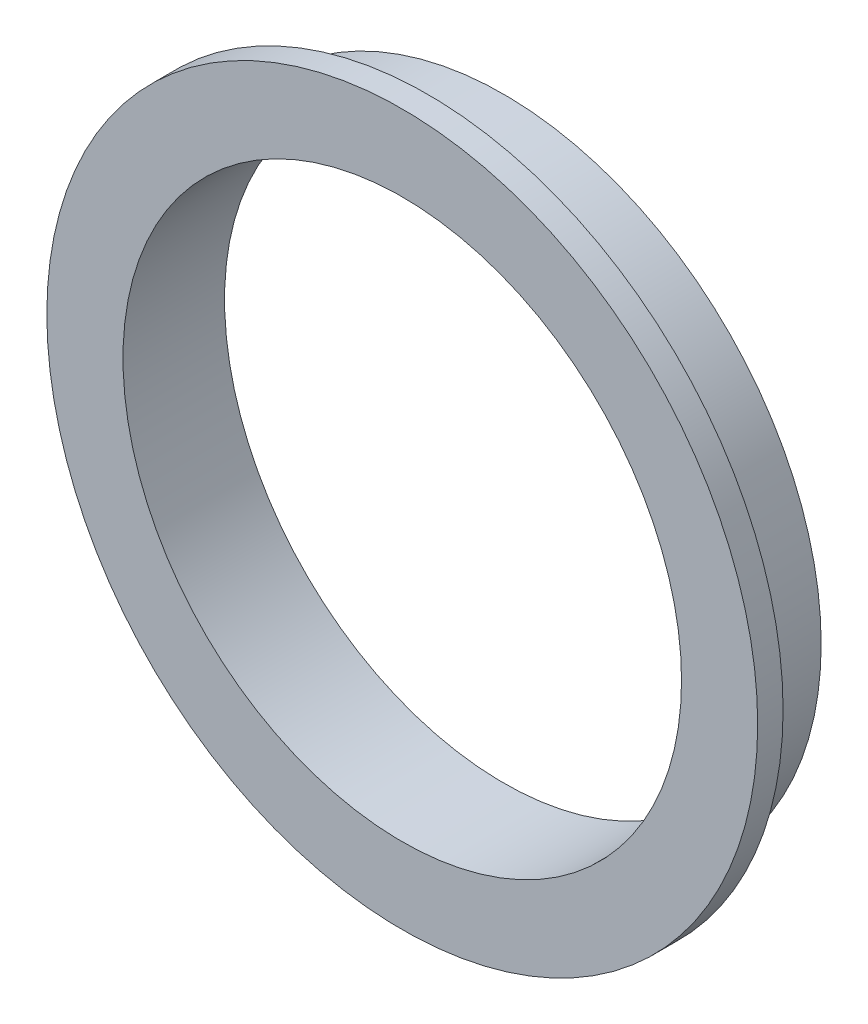
from build123d import *


with BuildPart() as part:
    # Sketch2 → Revolve1 (revolve)
    with BuildSketch(Plane(origin=(0, 0, 0), x_dir=(0, 0, -1), z_dir=(1, 0, 0))):
        Polygon((0, 69.85), (25.4, 69.85), (25.4, 73.025), (3.175, 73.025), (3.175, 76.2), (25.4, 76.2), (25.4, 79.375), (6.35, 79.375), (6.35, 88.9), (0, 88.9), align=None)
    revolve(axis=Axis((0, 0, 0), (0, 0, -1)))


solid = part.part
